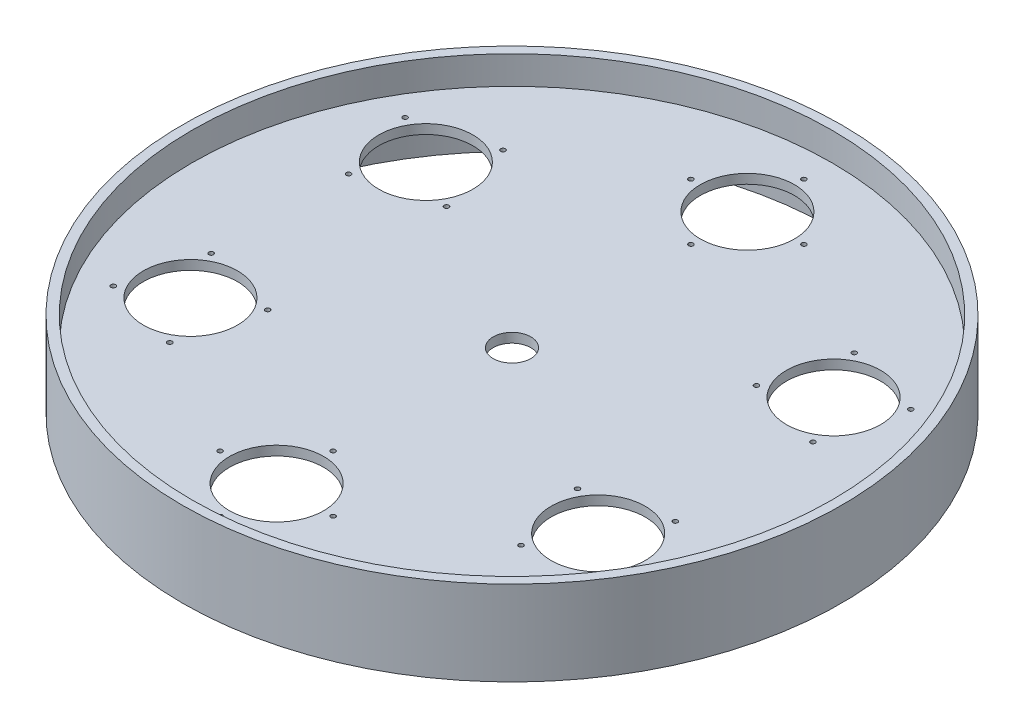
from build123d import *

# Parameters (mm, degrees)
CROQUIS1_R                   = 350
CROQUIS1_R_2                 = 50
CROQUIS1_R_3                 = 20
SALIENTE_EXTRUIR1_DEPTH      = 10
CROQUIS2_R                   = 350
CROQUIS2_R_2                 = 340
SALIENTE_EXTRUIR2_DEPTH      = 40
SALIENTE_EXTRUIR2_DEPTH_BACK = 50
CROQUIS5_R                   = 50
CROQUIS5_R_2                 = 2.5
CORTAR_EXTRUIR3_DEPTH        = 10


with BuildPart() as part:
    # Croquis1 → Saliente-Extruir1 (new body)
    with BuildSketch(Plane(origin=(0, 0, 0), x_dir=(1, 0, 0), z_dir=(0, 1, 0))):
        Circle(CROQUIS1_R)
        with Locations((0, 250)):
            Circle(CROQUIS1_R_2, mode=Mode.SUBTRACT)
        with Locations((216.506350946, 125)):
            Circle(CROQUIS1_R_2, mode=Mode.SUBTRACT)
        with Locations((216.506350946, -125)):
            Circle(CROQUIS1_R_2, mode=Mode.SUBTRACT)
        with Locations((0, -250)):
            Circle(CROQUIS1_R_2, mode=Mode.SUBTRACT)
        with Locations((-216.506350946, -125)):
            Circle(CROQUIS1_R_2, mode=Mode.SUBTRACT)
        with Locations((-216.506350946, 125)):
            Circle(CROQUIS1_R_2, mode=Mode.SUBTRACT)
        Circle(CROQUIS1_R_3, mode=Mode.SUBTRACT)
    extrude(amount=SALIENTE_EXTRUIR1_DEPTH)

    # Croquis2 → Saliente-Extruir2 (add, two sides)
    with BuildSketch(Plane(origin=(0, 0, 0), x_dir=(1, 0, 0), z_dir=(0, 1, 0))) as saliente_extruir2_sk:
        Circle(CROQUIS2_R)
        Circle(CROQUIS2_R_2, mode=Mode.SUBTRACT)
    extrude(amount=SALIENTE_EXTRUIR2_DEPTH)
    extrude(saliente_extruir2_sk.sketch, amount=-SALIENTE_EXTRUIR2_DEPTH_BACK)

    # Croquis5 → Cortar-Extruir3 (cut)
    with BuildSketch(Plane(origin=(0, 10, 0), x_dir=(1, 0, 0), z_dir=(0, 1, 0))):
        with Locations((0, 250)):
            Circle(CROQUIS5_R)
        with Locations((0, 310)):
            Circle(CROQUIS5_R_2)
        with Locations((60, 250)):
            Circle(CROQUIS5_R_2)
        with Locations((0, 190)):
            Circle(CROQUIS5_R_2)
        with Locations((-60, 250)):
            Circle(CROQUIS5_R_2)
        with Locations((268.467875173, 155)):
            Circle(CROQUIS5_R_2)
        with Locations((186.506350946, 176.961524227)):
            Circle(CROQUIS5_R_2)
        with Locations((246.506350946, 73.038475773)):
            Circle(CROQUIS5_R_2)
        with Locations((164.544826719, 95)):
            Circle(CROQUIS5_R_2)
        with Locations((268.467875173, -155)):
            Circle(CROQUIS5_R_2)
        with Locations((246.506350946, -73.038475773)):
            Circle(CROQUIS5_R_2)
        with Locations((186.506350946, -176.961524227)):
            Circle(CROQUIS5_R_2)
        with Locations((164.544826719, -95)):
            Circle(CROQUIS5_R_2)
        with Locations((0, -310)):
            Circle(CROQUIS5_R_2)
        with Locations((60, -250)):
            Circle(CROQUIS5_R_2)
        with Locations((-60, -250)):
            Circle(CROQUIS5_R_2)
        with Locations((0, -190)):
            Circle(CROQUIS5_R_2)
        with Locations((-268.467875173, -155)):
            Circle(CROQUIS5_R_2)
        with Locations((-186.506350946, -176.961524227)):
            Circle(CROQUIS5_R_2)
        with Locations((-246.506350946, -73.038475773)):
            Circle(CROQUIS5_R_2)
        with Locations((-164.544826719, -95)):
            Circle(CROQUIS5_R_2)
        with Locations((-268.467875173, 155)):
            Circle(CROQUIS5_R_2)
        with Locations((-246.506350946, 73.038475773)):
            Circle(CROQUIS5_R_2)
        with Locations((-186.506350946, 176.961524227)):
            Circle(CROQUIS5_R_2)
        with Locations((-164.544826719, 95)):
            Circle(CROQUIS5_R_2)
    extrude(amount=-CORTAR_EXTRUIR3_DEPTH, mode=Mode.SUBTRACT)


solid = part.part
